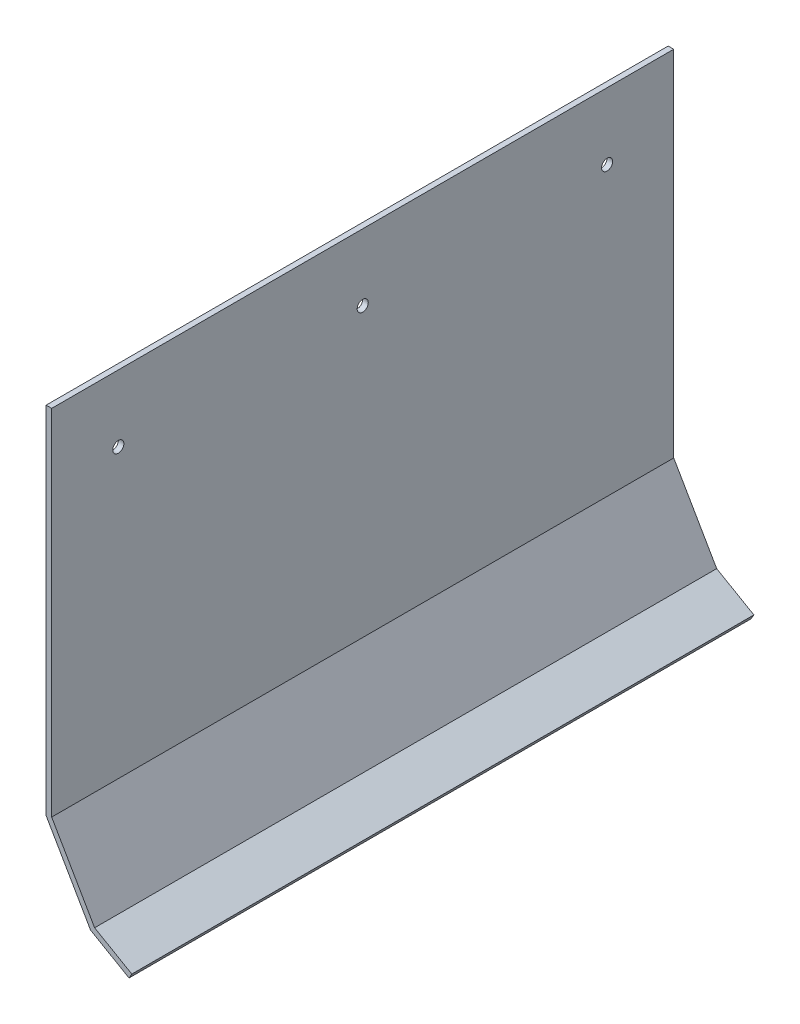
from build123d import *

# Parameters (mm, degrees)
EXTRUDE_1_DEPTH     = 177.8
SKETCH_2_R          = 1.5875
CUT_EXTRUDE_1_DEPTH = 254


with BuildPart() as part:
    # 스케치1 → 보스-돌출1 (new body)
    with BuildSketch(Plane.XY):
        Polygon((-34.442078201, -34.169098619), (-21.742078201, -56.166143875), (-10.743555573, -62.516143875), (-9.949805573, -61.141328546), (-20.579947544, -55.004013218), (-32.854578201, -33.743729276), (-32.854578201, 67.430901381), (-34.442078201, 67.430901381), align=None)
    extrude(amount=EXTRUDE_1_DEPTH)

    # 스케치2 → 컷-돌출1 (cut)
    with BuildSketch(Plane.ZY.offset(34.442078201)):
        with Locations((158.75, 48.380901381)):
            Circle(SKETCH_2_R)
        with Locations((88.9, 48.380901381)):
            Circle(SKETCH_2_R)
        with Locations((19.05, 48.380901381)):
            Circle(SKETCH_2_R)
    extrude(amount=-CUT_EXTRUDE_1_DEPTH, mode=Mode.SUBTRACT)


solid = part.part
